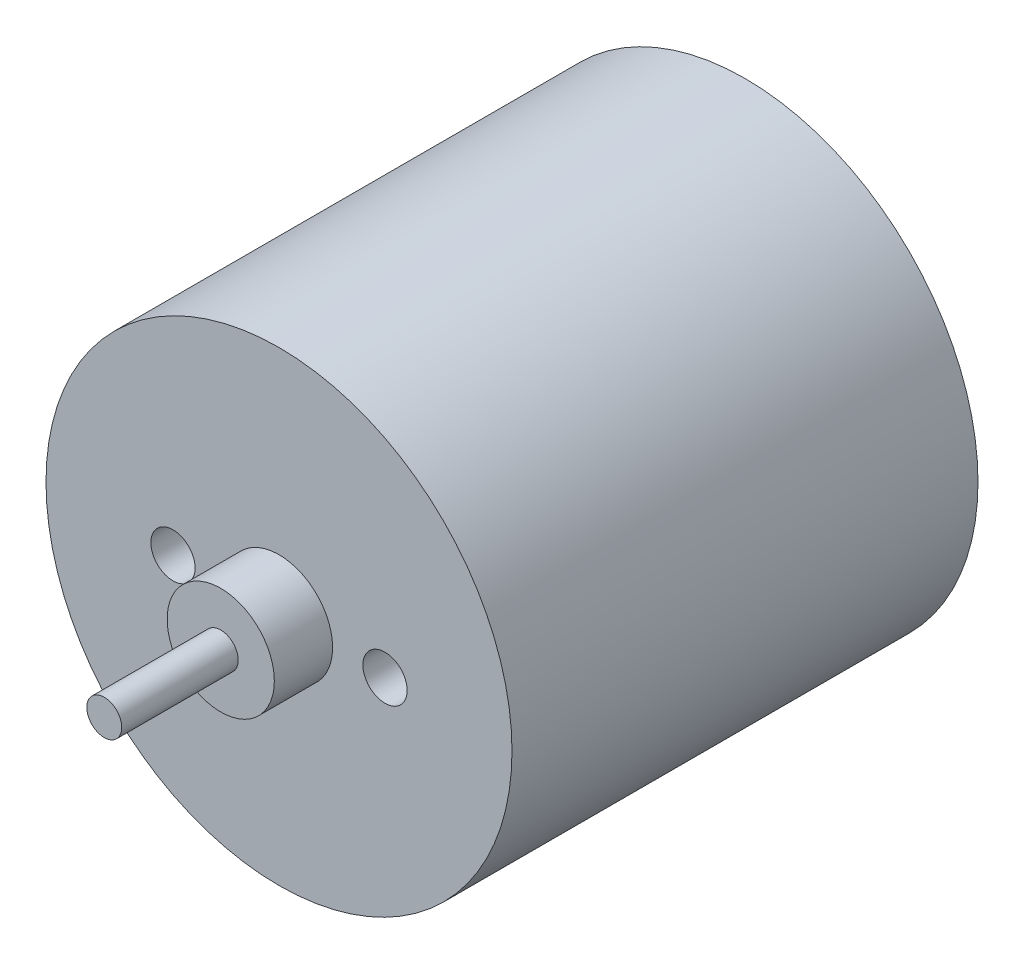
from build123d import *

# Parameters (mm, degrees)
SKETCH1_R           = 12.7
BOSS_EXTRUDE1_DEPTH = 25.4
SKETCH2_R           = 2.921
BOSS_EXTRUDE2_DEPTH = 3.175
SKETCH4_R           = 1.2065
CUT_EXTRUDE1_DEPTH  = 7.62
SKETCH6_R           = 0.9525
BOSS_EXTRUDE3_DEPTH = 6.35


with BuildPart() as part:
    # Sketch1 → Boss-Extrude1 (new body)
    with BuildSketch(Plane.XY):
        Circle(SKETCH1_R)
    extrude(amount=BOSS_EXTRUDE1_DEPTH)

    # Sketch2 → Boss-Extrude2 (add)
    with BuildSketch(Plane.XY.offset(25.4)):
        Circle(SKETCH2_R)
    extrude(amount=BOSS_EXTRUDE2_DEPTH)

    # Sketch4 → Cut-Extrude1 (cut)
    with BuildSketch(Plane.XY.offset(25.4)):
        with Locations((-5.7785, 0)):
            Circle(SKETCH4_R)
        with Locations((5.7785, 0)):
            Circle(SKETCH4_R)
    extrude(amount=-CUT_EXTRUDE1_DEPTH, mode=Mode.SUBTRACT)

    # Sketch6 → Boss-Extrude3 (add)
    with BuildSketch(Plane.XY.offset(28.575)):
        Circle(SKETCH6_R)
    extrude(amount=BOSS_EXTRUDE3_DEPTH)


solid = part.part
